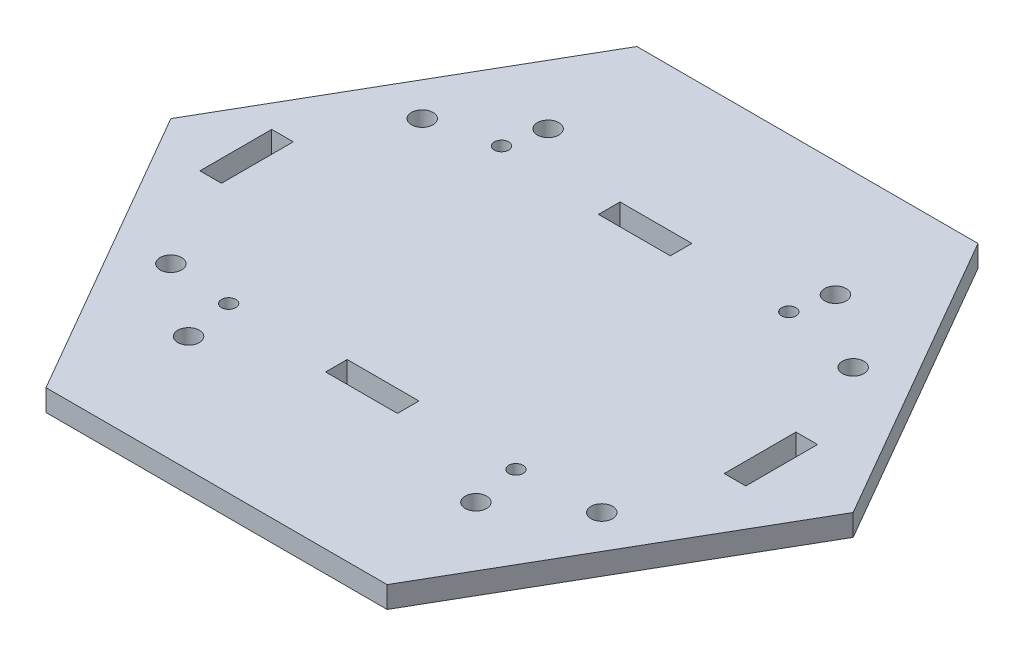
from build123d import *

# Parameters (mm, degrees)
SALIENTE_EXTRUIR1_DEPTH = 3
CROQUIS3_R              = 1
CROQUIS3_W              = 10
CROQUIS3_H              = 3
CROQUIS3_W_2            = 3
CROQUIS3_H_2            = 10
CORTAR_EXTRUIR1_DEPTH   = 4
CROQUIS4_R              = 1.5
CORTAR_EXTRUIR2_DEPTH   = 4
CROQUIS5_R              = 1.5
CORTAR_EXTRUIR3_DEPTH   = 4


with BuildPart() as part:
    # Croquis1 → Saliente-Extruir1 (new body)
    with BuildSketch(Plane(origin=(0, 0, 0), x_dir=(1, 0, 0), z_dir=(0, 1, 0))):
        Polygon((-47.5, 0), (-23.75, -41.13620668), (23.75, -41.13620668), (47.5, 0), (23.75, 41.13620668), (-23.75, 41.13620668), align=None)
    extrude(amount=SALIENTE_EXTRUIR1_DEPTH)

    # Croquis3 → Cortar-Extruir1 (cut, through all)
    with BuildSketch(Plane(origin=(0, 3, 0), x_dir=(1, 0, 0), z_dir=(0, 1, 0))):
        with Locations((-21.177619762, 19.723456661)):
            Circle(CROQUIS3_R)
        with Locations((18.822380238, 19.723456661)):
            Circle(CROQUIS3_R)
        with Locations((18.822380238, -18.276543339)):
            Circle(CROQUIS3_R)
        with Locations((-21.177619762, -18.276543339)):
            Circle(CROQUIS3_R)
        with Locations((-1.177619762, 19.723456661)):
            Rectangle(CROQUIS3_W, CROQUIS3_H)
        with Locations((35.322380238, 0.723456661)):
            Rectangle(CROQUIS3_W_2, CROQUIS3_H_2)
        with Locations((-1.177619762, -18.276543339)):
            Rectangle(CROQUIS3_W, CROQUIS3_H)
        with Locations((-37.677619762, 0.723456661)):
            Rectangle(CROQUIS3_W_2, CROQUIS3_H_2)
    extrude(amount=-CORTAR_EXTRUIR1_DEPTH, mode=Mode.SUBTRACT)

    # Croquis4 → Cortar-Extruir2 (cut, through all)
    with BuildSketch(Plane(origin=(0, 3, 0), x_dir=(1, 0, 0), z_dir=(0, 1, 0))):
        with Locations((20.005, -25.03)):
            Circle(CROQUIS4_R)
        with Locations((20.005, 25.03)):
            Circle(CROQUIS4_R)
        with Locations((-20.005, 25.03)):
            Circle(CROQUIS4_R)
        with Locations((-20.005, -25.03)):
            Circle(CROQUIS4_R)
    extrude(amount=-CORTAR_EXTRUIR2_DEPTH, mode=Mode.SUBTRACT)

    # Croquis5 → Cortar-Extruir3 (cut, through all)
    with BuildSketch(Plane(origin=(0, 3, 0), x_dir=(1, 0, 0), z_dir=(0, 1, 0))):
        with Locations((30, 17.5)):
            Circle(CROQUIS5_R)
        with Locations((30, -17.5)):
            Circle(CROQUIS5_R)
        with Locations((-30, -17.5)):
            Circle(CROQUIS5_R)
        with Locations((-30, 17.5)):
            Circle(CROQUIS5_R)
    extrude(amount=-CORTAR_EXTRUIR3_DEPTH, mode=Mode.SUBTRACT)


solid = part.part
